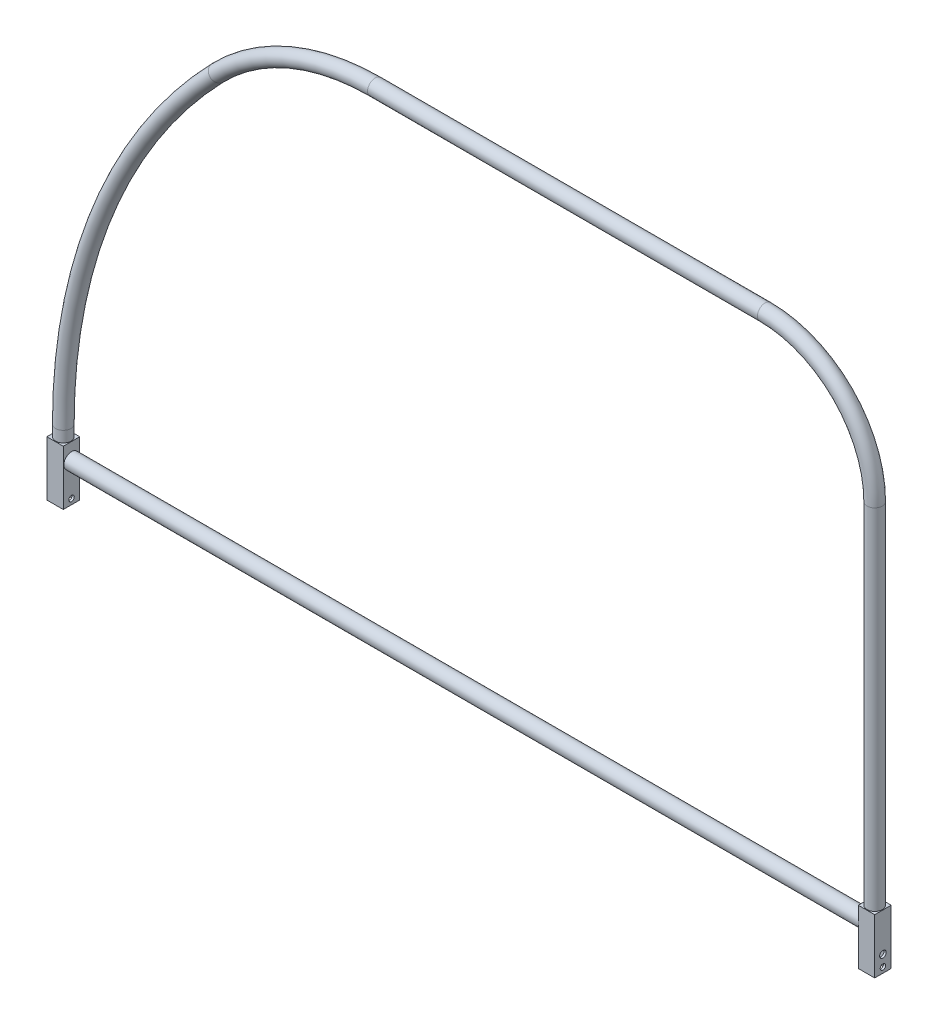
from build123d import *

# Parameters (mm, degrees)
SWEEP1_PROFILE_R    = 8.89
SKETCH107_W         = 19.05
SKETCH107_H         = 19.05
BOSS_EXTRUDE1_DEPTH = 63.5
SWEEP3_PROFILE_R    = 8.89
SHELL17_T           = -2.54
SKETCH115_R         = 3.175
CUT_EXTRUDE1_DEPTH  = 959.85
SKETCH119_R         = 3.81
CUT_EXTRUDE2_DEPTH  = 2.54
SKETCH120_R         = 3.81
CUT_EXTRUDE3_DEPTH  = 2.54


with BuildPart() as part:
    # Sweep1: sweep along a path in Sketch80
    with BuildLine(Plane.XY) as sweep1_path:
        Line((0, 0), (0, 12.7))
        ThreePointArc((0, 12.7), (46.415688716, 251.013886523), (178.877192157, 454.488392973))
        ThreePointArc((178.877192157, 454.488392973), (262.254878255, 511.655164992), (361.326315294, 531.773035784))
        Line((361.326315294, 531.773035784), (812.8, 531.773035784))
        ThreePointArc((812.8, 531.773035784), (902.602561211, 494.575596994), (939.8, 404.773035784))
        Line((939.8, 404.773035784), (939.8, -14.326964216))
    # Sweep1 profile (on start of the path) → Sweep1 (sweep)
    with BuildSketch(Plane.ZX):
        Circle(SWEEP1_PROFILE_R)
    sweep(path=sweep1_path.line)

    # Sketch107 → Boss-Extrude1 (add)
    with BuildSketch(Plane.XZ):
        Rectangle(SKETCH107_W, SKETCH107_H)
        with Locations((939.8, 0)):
            Rectangle(SKETCH107_W, SKETCH107_H)
    extrude(amount=BOSS_EXTRUDE1_DEPTH)

    # Sweep3: sweep along a path in Sketch108
    with BuildLine(Plane.XY) as sweep3_path:
        Line((9.525, -19.05), (930.275, -19.05))
    # Sweep3 profile (on start of the path) → Sweep3 (sweep)
    with BuildSketch(Plane(origin=(9.525, -19.05, 0), x_dir=(0, 0, 1), z_dir=(1, 0, 0))):
        Circle(SWEEP3_PROFILE_R)
    sweep(path=sweep3_path.line)

    # Shell17
    shell17_openings = [part.faces().sort_by_distance(p)[0] for p in [
        (0, -63.5, 0),
        (939.8, -63.5, 0),
    ]]
    offset(amount=SHELL17_T, openings=shell17_openings, kind=Kind.INTERSECTION)

    # Sketch115 → Cut-Extrude1 (cut, through all)
    with BuildSketch(Plane.ZY.offset(9.525)):
        with Locations((0, -57.15)):
            Circle(SKETCH115_R)
    extrude(amount=-CUT_EXTRUDE1_DEPTH, mode=Mode.SUBTRACT)

    # Sketch119 → Cut-Extrude2 (cut)
    with BuildSketch(Plane(origin=(949.325, 0, 0), x_dir=(0, 0, -1), z_dir=(1, 0, 0))):
        with Locations((0, -44.45)):
            Circle(SKETCH119_R)
    extrude(amount=-CUT_EXTRUDE2_DEPTH, mode=Mode.SUBTRACT)

    # Sketch120 → Cut-Extrude3 (cut)
    with BuildSketch(Plane.ZY.offset(9.525)):
        with Locations((0, -44.45)):
            Circle(SKETCH120_R)
    extrude(amount=-CUT_EXTRUDE3_DEPTH, mode=Mode.SUBTRACT)


solid = part.part
